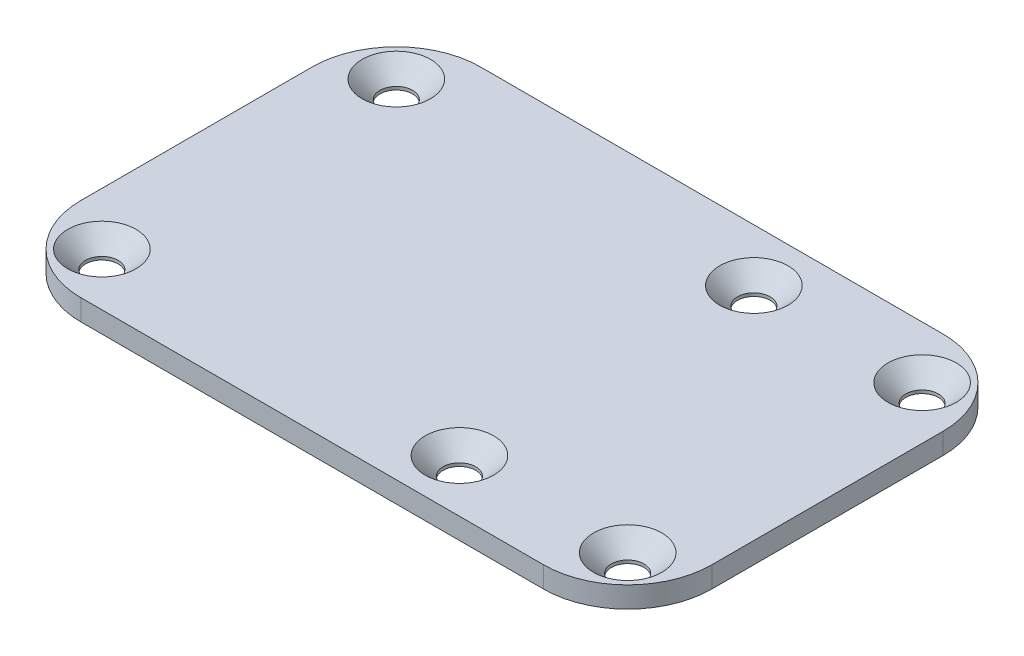
from build123d import *

# Parameters (mm, degrees)
BOSS_EXTRUDE1_DEPTH                 = 2
F_3_1_3_1_DIAMETER_HOLE1_AT_2_COUNT = 2
F_3_1_3_1_DIAMETER_HOLE1_AT_2_PITCH = 28
F_3_1_3_1_DIAMETER_HOLE1_AT_3_COUNT = 2
F_3_1_3_1_DIAMETER_HOLE1_AT_3_PITCH = 57.306195128
F_3_1_3_1_DIAMETER_HOLE1_AT_4_COUNT = 2
F_3_1_3_1_DIAMETER_HOLE1_AT_4_PITCH = 50
F_3_1_3_1_DIAMETER_HOLE1_AT_5_COUNT = 2
F_3_1_3_1_DIAMETER_HOLE1_AT_5_PITCH = 16
F_3_1_3_1_DIAMETER_HOLE1_AT_6_COUNT = 2
F_3_1_3_1_DIAMETER_HOLE1_AT_6_PITCH = 32.249030993


with BuildPart() as part:
    # Sketch1 → Boss-Extrude1 (new body)
    with BuildSketch(Plane(origin=(0, 0, 0), x_dir=(1, 0, 0), z_dir=(0, 1, 0))):
        with BuildLine():
            Line((22, -19), (-22, -19))
            ThreePointArc((-22, -19), (-27.656854249, -16.656854249), (-30, -11))
            Line((-30, -11), (-30, 11))
            ThreePointArc((-30, 11), (-27.656854249, 16.656854249), (-22, 19))
            Line((-22, 19), (22, 19))
            ThreePointArc((22, 19), (27.656854249, 16.656854249), (30, 11))
            Line((30, 11), (30, -11))
            ThreePointArc((30, -11), (27.656854249, -16.656854249), (22, -19))
        make_face()
    extrude(amount=BOSS_EXTRUDE1_DEPTH)

    # Hole → Ø3.1 (3.1) Diameter Hole1 (revolve, cut)
    with BuildSketch(Plane(origin=(25, 2, -14), x_dir=(0, 0, 1), z_dir=(1, 0, 0))):
        Polygon((0, 0), (0, 2), (1.55, 2), (1.55, 1.7), (3.25, 0), align=None)
    f_3_1_3_1_diameter_hole1 = revolve(axis=Axis((25, 8.35, -14), (0, -1, 0)), mode=Mode.SUBTRACT)

    # Ø3.1 (3.1) Diameter Hole1 at 2: Ø3.1 (3.1) Diameter Hole1 ×2
    with Locations(*[(0, 0, i * F_3_1_3_1_DIAMETER_HOLE1_AT_2_PITCH) for i in range(1, F_3_1_3_1_DIAMETER_HOLE1_AT_2_COUNT)]):
        add(f_3_1_3_1_diameter_hole1, mode=Mode.SUBTRACT)

    # Ø3.1 (3.1) Diameter Hole1 at 3: Ø3.1 (3.1) Diameter Hole1 ×2
    with Locations(*[Vector(-0.872506016, 0, 0.488603369) * (i * F_3_1_3_1_DIAMETER_HOLE1_AT_3_PITCH) for i in range(1, F_3_1_3_1_DIAMETER_HOLE1_AT_3_COUNT)]):
        add(f_3_1_3_1_diameter_hole1, mode=Mode.SUBTRACT)

    # Ø3.1 (3.1) Diameter Hole1 at 4: Ø3.1 (3.1) Diameter Hole1 ×2
    with Locations(*[(-i * F_3_1_3_1_DIAMETER_HOLE1_AT_4_PITCH, 0, 0) for i in range(1, F_3_1_3_1_DIAMETER_HOLE1_AT_4_COUNT)]):
        add(f_3_1_3_1_diameter_hole1, mode=Mode.SUBTRACT)

    # Ø3.1 (3.1) Diameter Hole1 at 5: Ø3.1 (3.1) Diameter Hole1 ×2
    with Locations(*[(-i * F_3_1_3_1_DIAMETER_HOLE1_AT_5_PITCH, 0, 0) for i in range(1, F_3_1_3_1_DIAMETER_HOLE1_AT_5_COUNT)]):
        add(f_3_1_3_1_diameter_hole1, mode=Mode.SUBTRACT)

    # Ø3.1 (3.1) Diameter Hole1 at 6: Ø3.1 (3.1) Diameter Hole1 ×2
    with Locations(*[Vector(-0.496138938, 0, 0.868243142) * (i * F_3_1_3_1_DIAMETER_HOLE1_AT_6_PITCH) for i in range(1, F_3_1_3_1_DIAMETER_HOLE1_AT_6_COUNT)]):
        add(f_3_1_3_1_diameter_hole1, mode=Mode.SUBTRACT)


solid = part.part
